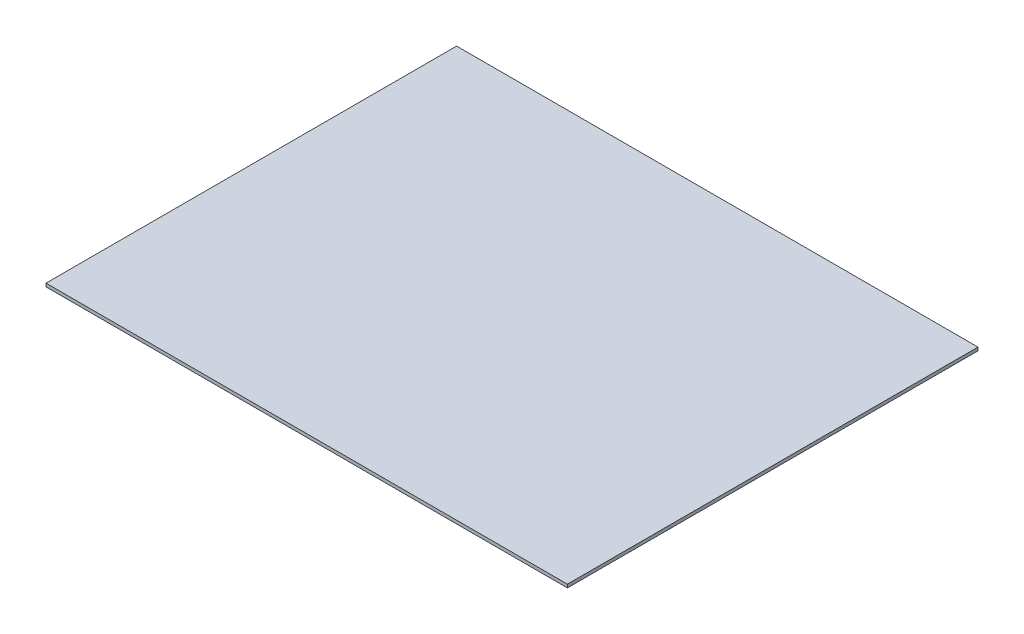
from build123d import *

# Parameters (mm, degrees)
SKETCH1_W           = 2032
SKETCH1_H           = 1600.2
BOSS_EXTRUDE1_DEPTH = 12.7


with BuildPart() as part:
    # Sketch1 → Boss-Extrude1 (new body)
    with BuildSketch(Plane(origin=(0, 0, 0), x_dir=(1, 0, 0), z_dir=(0, 1, 0))):
        with Locations((1016, 800.1)):
            Rectangle(SKETCH1_W, SKETCH1_H)
    extrude(amount=BOSS_EXTRUDE1_DEPTH)


solid = part.part
